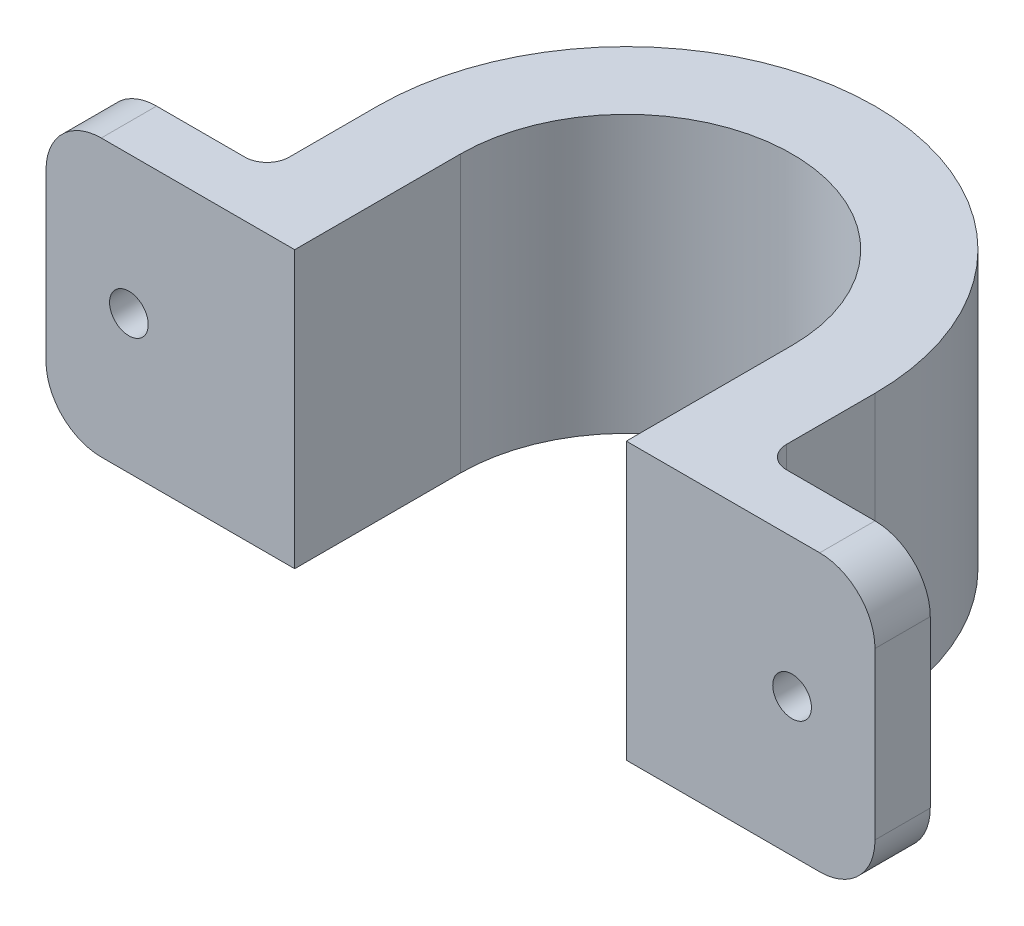
from build123d import *

# Parameters (mm, degrees)
BOSS_EXTRUDE1_DEPTH = 25
SKETCH4_R           = 1.75
CUT_EXTRUDE1_DEPTH  = 6
FILLET1_R           = 5
FILLET2_R           = 2


with BuildPart() as part:
    # Sketch1 → Boss-Extrude1 (new body)
    with BuildSketch(Plane(origin=(0, 0, 0), x_dir=(1, 0, 0), z_dir=(0, 1, 0))):
        with BuildLine():
            Line((-7.5, 0), (-7.5, -10))
            Line((-7.5, -10), (-22.5, -10))
            Line((-22.5, -10), (-22.5, -15))
            Line((-22.5, -15), (0, -15))
            Line((0, -15), (0, 0))
            ThreePointArc((0, 0), (15, 15), (30, 0))
            Line((30, 0), (30, -15))
            Line((30, -15), (52.5, -15))
            Line((52.5, -15), (52.5, -10))
            Line((52.5, -10), (37.5, -10))
            Line((37.5, -10), (37.5, 0))
            ThreePointArc((37.5, 0), (15, 22.5), (-7.5, 0))
        make_face()
    extrude(amount=BOSS_EXTRUDE1_DEPTH)

    # Sketch4 → Cut-Extrude1 (cut, through all)
    with BuildSketch(Plane(origin=(0, 0, 10), x_dir=(-1, 0, 0), z_dir=(0, 0, -1))):
        with Locations((-45, 12.5)):
            Circle(SKETCH4_R)
        with Locations((15, 12.5)):
            Circle(SKETCH4_R)
    extrude(amount=-CUT_EXTRUDE1_DEPTH, mode=Mode.SUBTRACT)

    # Fillet1
    fillet1_edges = [part.edges().sort_by_distance(p)[0] for p in [
        (-22.5, 0, 12.5),
        (52.5, 0, 12.5),
        (52.5, 25, 12.5),
        (-22.5, 25, 12.5),
    ]]
    fillet(fillet1_edges, radius=FILLET1_R)

    # Fillet2
    fillet2_edges = [part.edges().sort_by_distance(p)[0] for p in [
        (-7.5, 12.5, 10),
        (37.5, 12.5, 10),
    ]]
    fillet(fillet2_edges, radius=FILLET2_R)


solid = part.part
